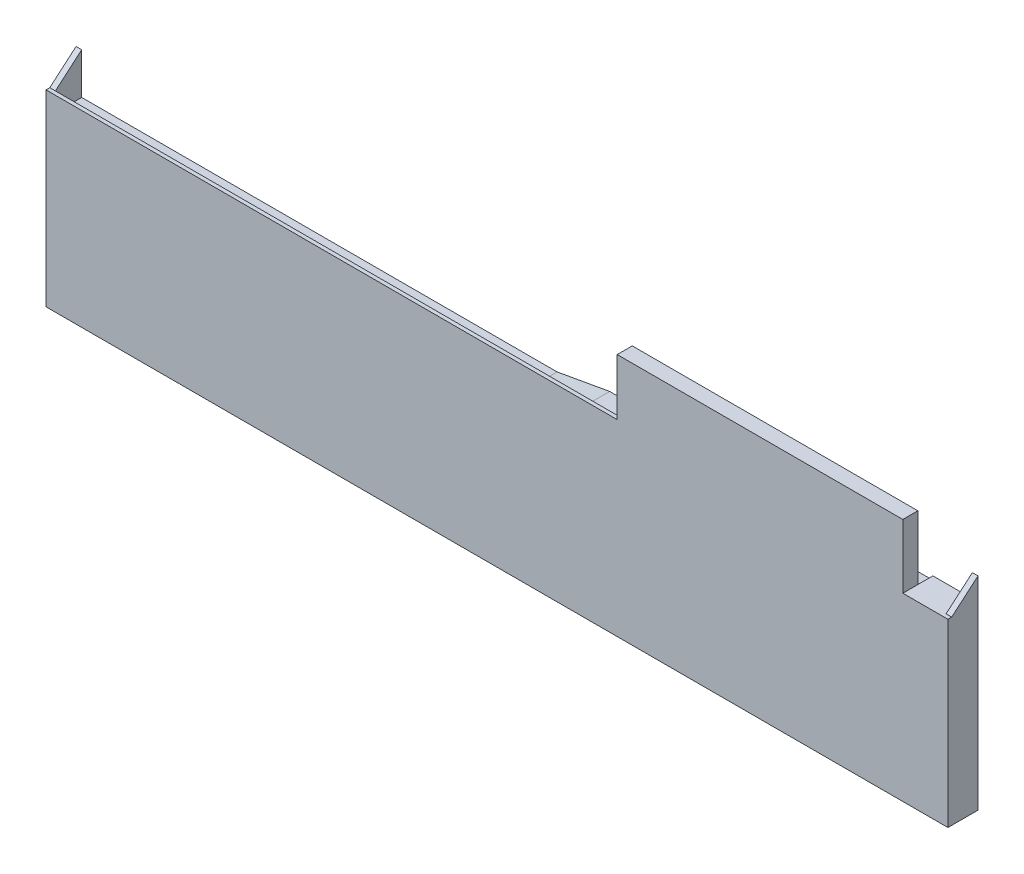
from build123d import *

# Parameters (mm, degrees)
SALIENTE_EXTRUIR1_DEPTH = 8
CROQUIS6_W              = 152
CROQUIS6_H              = 1.5
CORTAR_EXTRUIR10_DEPTH  = 1.5
CORTAR_EXTRUIR12_DEPTH  = 128
CROQUIS12_W             = 24
CROQUIS12_H             = 5.5
CORTAR_EXTRUIR13_DEPTH  = 1.5
CORTAR_EXTRUIR14_DEPTH  = 5.5
CORTAR_EXTRUIR16_DEPTH  = 1.5
CROQUIS17_W             = 76
CROQUIS17_H             = 4
CORTAR_EXTRUIR17_DEPTH  = 18
CROQUIS18_W             = 10
CROQUIS18_H             = 5.5
CORTAR_EXTRUIR18_DEPTH  = 1
CORTAR_EXTRUIR22_DEPTH  = 5
CORTAR_EXTRUIR23_DEPTH  = 0.5
CORTAR_EXTRUIR25_DEPTH  = 1.5
SALIENTE_EXTRUIR3_DEPTH = 1.5
SALIENTE_EXTRUIR4_DEPTH = 1.5


with BuildPart() as part:
    # Croquis2 → Saliente-Extruir1 (new body)
    with BuildSketch(Plane.XY):
        Polygon((0, 0), (240, 0), (240, 48), (228, 48), (228, 65), (152, 65), (152, 50), (0, 50), align=None)
    extrude(amount=SALIENTE_EXTRUIR1_DEPTH)

    # Croquis6 → Cortar-Extruir10 (cut)
    with BuildSketch(Plane(origin=(0, 50, 0), x_dir=(1, 0, 0), z_dir=(0, 1, 0))):
        with Locations((76, -6.25)):
            Rectangle(CROQUIS6_W, CROQUIS6_H)
    extrude(amount=-CORTAR_EXTRUIR10_DEPTH, mode=Mode.SUBTRACT)

    # Croquis9 → Cortar-Extruir12 (cut)
    with BuildSketch(Plane.ZY):
        Polygon((5.5, 48.5), (5.5, 46.5), (6.5, 46.5), (6.5, 45), (0, 45), (0, 50), (5.5, 50), align=None)
    extrude(amount=-CORTAR_EXTRUIR12_DEPTH, mode=Mode.SUBTRACT)

    # Croquis12 → Cortar-Extruir13 (cut)
    with BuildSketch(Plane(origin=(0, 50, 0), x_dir=(1, 0, 0), z_dir=(0, 1, 0))):
        with Locations((140, -2.75)):
            Rectangle(CROQUIS12_W, CROQUIS12_H)
    extrude(amount=-CORTAR_EXTRUIR13_DEPTH, mode=Mode.SUBTRACT)

    # Croquis13 → Cortar-Extruir14 (cut)
    with BuildSketch(Plane(origin=(0, 0, 0), x_dir=(-1, 0, 0), z_dir=(0, 0, -1))):
        Polygon((-142, 48.5), (-128, 45), (-128, 48.5), align=None)
    extrude(amount=-CORTAR_EXTRUIR14_DEPTH, mode=Mode.SUBTRACT)

    # Croquis14 → Cortar-Extruir16 (cut)
    with BuildSketch(Plane(origin=(0, 0, 5.5), x_dir=(-1, 0, 0), z_dir=(0, 0, -1))):
        Polygon((-128, 45), (-128, 46.5), (-134, 46.5), align=None)
    extrude(amount=-CORTAR_EXTRUIR16_DEPTH, mode=Mode.SUBTRACT)

    # Croquis17 → Cortar-Extruir17 (cut)
    with BuildSketch(Plane(origin=(0, 65, 0), x_dir=(1, 0, 0), z_dir=(0, 1, 0))):
        with Locations((190, -2)):
            Rectangle(CROQUIS17_W, CROQUIS17_H)
    extrude(amount=-CORTAR_EXTRUIR17_DEPTH, mode=Mode.SUBTRACT)

    # Croquis18 → Cortar-Extruir18 (cut)
    with BuildSketch(Plane(origin=(0, 48.5, 0), x_dir=(1, 0, 0), z_dir=(0, 1, 0))):
        with Locations((147, -2.75)):
            Rectangle(CROQUIS18_W, CROQUIS18_H)
    extrude(amount=-CORTAR_EXTRUIR18_DEPTH, mode=Mode.SUBTRACT)

    # Croquis19 → Cortar-Extruir22 (cut)
    with BuildSketch(Plane(origin=(0, 0, 0), x_dir=(-1, 0, 0), z_dir=(0, 0, -1))):
        Polygon((-142, 47.5), (-128, 45), (-142, 48.5), align=None)
    extrude(amount=-CORTAR_EXTRUIR22_DEPTH, mode=Mode.SUBTRACT)

    # Croquis20 → Cortar-Extruir23 (cut)
    with BuildSketch(Plane(origin=(0, 0, 5), x_dir=(-1, 0, 0), z_dir=(0, 0, -1))):
        Polygon((-142, 48.5), (-142, 47.5), (-128, 45), align=None)
    extrude(amount=-CORTAR_EXTRUIR23_DEPTH, mode=Mode.SUBTRACT)

    # Croquis21 → Cortar-Extruir25 (cut)
    with BuildSketch(Plane(origin=(0, 0, 5.5), x_dir=(-1, 0, 0), z_dir=(0, 0, -1))):
        Polygon((-134, 46.5), (-136.4, 46.5), (-134, 46.071428571), (-128, 45), align=None)
    extrude(amount=-CORTAR_EXTRUIR25_DEPTH, mode=Mode.SUBTRACT)

    # Croquis22 → Saliente-Extruir3 (add)
    with BuildSketch(Plane(origin=(240, 0, 0), x_dir=(0, 0, -1), z_dir=(1, 0, 0))):
        Polygon((0, 48), (0, 54), (-7, 48), align=None)
    extrude(amount=-SALIENTE_EXTRUIR3_DEPTH)

    # Croquis23 → Saliente-Extruir4 (add)
    with BuildSketch(Plane.ZY):
        Polygon((0, 50), (0, 56), (7, 50), (7, 48.5), (5.5, 48.5), (5.5, 46.5), (6.5, 46.5), (6.5, 45), (0, 45), align=None)
    extrude(amount=-SALIENTE_EXTRUIR4_DEPTH)


solid = part.part
